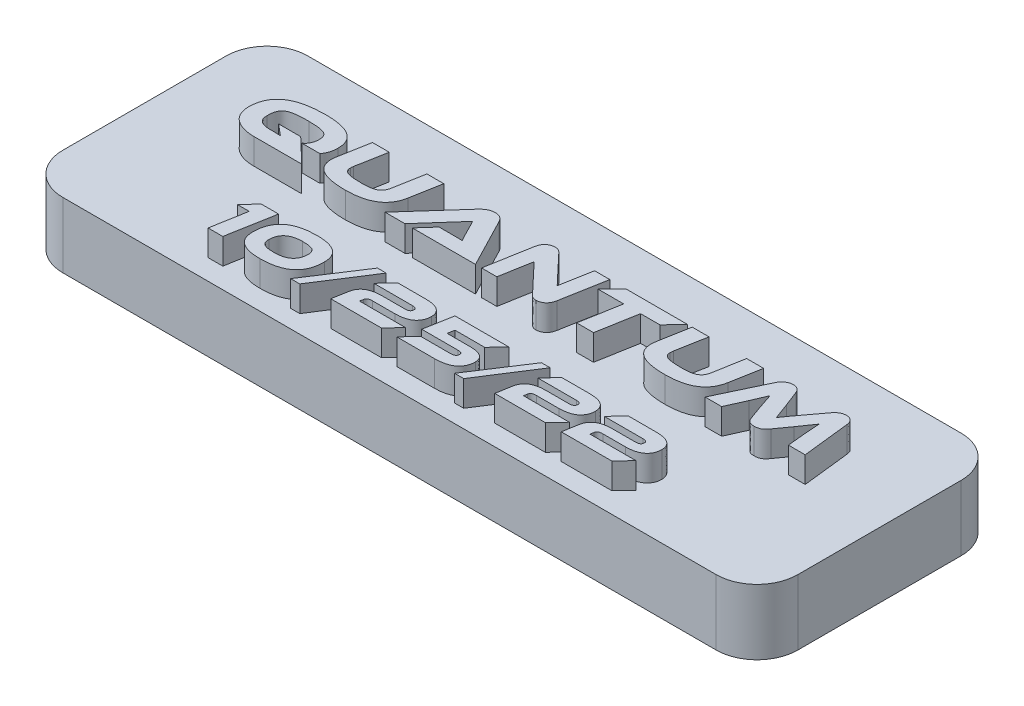
from build123d import *

# Parameters (mm, degrees)
SKETCH1_W           = 57.15
SKETCH1_H           = 19.05
BOSS_EXTRUDE1_DEPTH = 5.08
FILLET1_R           = 3.175
BOSS_EXTRUDE2_DEPTH = 2
SKETCH4_R           = 0.9
CUT_EXTRUDE1_DEPTH  = 4


with BuildPart() as part:
    # Sketch1 → Boss-Extrude1 (new body)
    with BuildSketch(Plane(origin=(0, 0, 0), x_dir=(1, 0, 0), z_dir=(0, 1, 0))):
        Rectangle(SKETCH1_W, SKETCH1_H)
    extrude(amount=BOSS_EXTRUDE1_DEPTH)

    # Fillet1
    fillet1_edges = [part.edges().sort_by_distance(p)[0] for p in [
        (-28.575, 2.54, -9.525),
        (-28.575, 2.54, 9.525),
        (28.575, 2.54, 9.525),
        (28.575, 2.54, -9.525),
    ]]
    fillet(fillet1_edges, radius=FILLET1_R)

    # Sketch3 → Boss-Extrude2 (add)
    with BuildSketch(Plane(origin=(0, 5.08, 0), x_dir=(1, 0, 0), z_dir=(0, 1, 0))):
        with BuildLine():
            add(Edge.make_bspline(
                [(18.242658301, 3.821864298), (18.228626929, 3.854947842), (18.20117453, 3.919675843), (18.146878265, 4.00785825), (18.083346334, 4.084680144), (18.01027638, 4.150072297), (17.925407832, 4.202261522), (17.828550464, 4.239681634), (17.719705347, 4.261491707), (17.643589857, 4.264690453), (17.603874928, 4.266359469)],
                knots=[0, 0, 0, 0, 0.000107692, 0.0002107, 0.00030937, 0.000405859, 0.000503537, 0.000606581, 0.000715765, 0.000834889, 0.000834889, 0.000834889, 0.000834889], degree=3))
            add(Edge.make_bspline(
                [(17.603874928, 4.266359469), (17.56259615, 4.264911976), (17.480084848, 4.262018611), (17.358319642, 4.234270285), (17.23991769, 4.188827027), (17.125926082, 4.125361681), (17.016789614, 4.045413244), (16.919972177, 3.943118147), (16.829908651, 3.825335584), (16.782034088, 3.735707046), (16.757367778, 3.689527923)],
                knots=[0, 0, 0, 0, 0.000123685, 0.000247231, 0.000372524, 0.000503046, 0.00063761, 0.000776601, 0.000924145, 0.00108096, 0.00108096, 0.00108096, 0.00108096], degree=3))
            Line((16.757367778, 3.689527923), (15.013783946, 0.003655726))
            Line((15.013783946, 0.003655726), (16.296487457, 0.003655726))
            Line((16.296487457, 0.003655726), (16.953636054, 1.464481009))
            add(Edge.make_bspline(
                [(16.953636054, 1.464481009), (16.977865812, 1.519909601), (17.025493838, 1.628864646), (17.094365231, 1.789446184), (17.161636319, 1.942964846), (17.224391525, 2.090413825), (17.284969187, 2.230959426), (17.341661284, 2.365338229), (17.394541541, 2.493505747), (17.428960337, 2.576699716), (17.445726184, 2.617224589)],
                knots=[0, 0, 0, 0, 0.000181479, 0.000356729, 0.00052418, 0.000684305, 0.000837469, 0.000983313, 0.001121843, 0.001253412, 0.001253412, 0.001253412, 0.001253412], degree=3))
            add(Edge.make_bspline(
                [(17.445726184, 2.617224589), (17.4559709, 2.582146896), (17.47721342, 2.509412955), (17.512585937, 2.396952832), (17.549310097, 2.276154433), (17.592645246, 2.146346616), (17.640529763, 2.002632754), (17.69660805, 1.841123618), (17.761748798, 1.659810645), (17.807449621, 1.531826555), (17.83149942, 1.464475652)],
                knots=[0, 0, 0, 0, 0.000109626, 0.000227311, 0.000353666, 0.000488379, 0.000637834, 0.000808115, 0.001001264, 0.001215812, 0.001215812, 0.001215812, 0.001215812], degree=3))
            Line((17.83149942, 1.464475652), (18.211064619, 0.404912456))
            add(Edge.make_bspline(
                [(18.211064619, 0.404912456), (18.229239325, 0.359535583), (18.263194741, 0.27475894), (18.32915974, 0.165066891), (18.400458371, 0.079389949), (18.481519793, 0.020148619), (18.570040737, -0.017188774), (18.6653744, -0.042938659), (18.769939175, -0.056575195), (18.842519564, -0.05604004), (18.880034734, -0.05576343)],
                knots=[0, 0, 0, 0, 0.000146435, 0.000273581, 0.000382454, 0.000478632, 0.000571543, 0.000669118, 0.00077423, 0.000886686, 0.000886686, 0.000886686, 0.000886686], degree=3))
            add(Edge.make_bspline(
                [(18.880034734, -0.05576343), (18.917850936, -0.055992745), (18.99224091, -0.056443841), (19.1016701, -0.042717291), (19.205783554, -0.015563104), (19.307848686, 0.022829401), (19.409032652, 0.083036928), (19.51025564, 0.169070984), (19.614708485, 0.280708265), (19.679879451, 0.367692811), (19.714657874, 0.414112029)],
                knots=[0, 0, 0, 0, 0.00011337, 0.000223015, 0.000329662, 0.000435594, 0.000549104, 0.000680897, 0.00083287, 0.001006773, 0.001006773, 0.001006773, 0.001006773], degree=3))
            Line((19.714657874, 0.414112029), (20.466853552, 1.465200548))
            add(Edge.make_bspline(
                [(20.466853552, 1.465200548), (20.513035851, 1.529169794), (20.601434083, 1.651614289), (20.726219205, 1.828381807), (20.839932507, 1.987679293), (20.94049218, 2.133154937), (21.032320436, 2.266547935), (21.11700732, 2.390994455), (21.195140755, 2.508743118), (21.244700795, 2.584889894), (21.268720676, 2.621795362)],
                knots=[0, 0, 0, 0, 0.000236691, 0.000453055, 0.000649121, 0.000823842, 0.000983589, 0.001134958, 0.00127542, 0.001407521, 0.001407521, 0.001407521, 0.001407521], degree=3))
            add(Edge.make_bspline(
                [(21.268720676, 2.621795362), (21.270954648, 2.536757041), (21.275545404, 2.362005428), (21.289585918, 2.139966033), (21.30225339, 1.952236415), (21.31583103, 1.800289613), (21.329013373, 1.638717755), (21.339306284, 1.52784762), (21.344595507, 1.470874734)],
                knots=[0, 0, 0, 0, 0.000255182, 0.000524392, 0.000667354, 0.000819643, 0.000982028, 0.00115368, 0.00115368, 0.00115368, 0.00115368], degree=3))
            Line((21.344595507, 1.470874734), (21.490488866, 0.003655726))
            Line((21.490488866, 0.003655726), (22.792148587, 0.003655726))
            Line((22.792148587, 0.003655726), (22.375111977, 3.690201933))
            add(Edge.make_bspline(
                [(22.375111977, 3.690201933), (22.367746579, 3.735767572), (22.353673096, 3.822832418), (22.308826278, 3.942054526), (22.249844088, 4.044898175), (22.170812965, 4.125995793), (22.080539998, 4.189905999), (21.978985664, 4.235155569), (21.867104165, 4.262540065), (21.789036598, 4.265057293), (21.748651836, 4.266359469)],
                knots=[0, 0, 0, 0, 0.000138154, 0.000263979, 0.000379994, 0.000491206, 0.000600771, 0.000710019, 0.000822876, 0.000943824, 0.000943824, 0.000943824, 0.000943824], degree=3))
            add(Edge.make_bspline(
                [(21.748651836, 4.266359469), (21.70680633, 4.264315029), (21.624932239, 4.26031492), (21.506004755, 4.237458819), (21.395100573, 4.198932407), (21.293079692, 4.144580626), (21.197494123, 4.0797862), (21.110011394, 4.002630646), (21.02630324, 3.917859546), (20.977930349, 3.853756483), (20.953337343, 3.821166184)],
                knots=[0, 0, 0, 0, 0.000125572, 0.000245692, 0.000361916, 0.000476404, 0.000591519, 0.00070753, 0.000825838, 0.000948192, 0.000948192, 0.000948192, 0.000948192], degree=3))
            Line((20.953337343, 3.821166184), (20.062454416, 2.63063338))
            add(Edge.make_bspline(
                [(20.062454416, 2.63063338), (20.033362193, 2.592038973), (19.97675682, 2.516944994), (19.894403746, 2.40752977), (19.817874467, 2.303579542), (19.744321831, 2.207146967), (19.676583973, 2.115786728), (19.614900781, 2.029366729), (19.55615978, 1.950451781), (19.486593746, 1.854220433), (19.406713414, 1.742020151), (19.318060484, 1.614517972), (19.238572969, 1.49522478), (19.188370896, 1.418793145), (19.164336812, 1.382201739)],
                knots=[0, 0, 0, 0, 0.000144993, 0.000282116, 0.00041083, 0.000532231, 0.000645954, 0.000752012, 0.000850745, 0.000941075, 0.001108235, 0.001263934, 0.001406932, 0.001538268, 0.001538268, 0.001538268, 0.001538268], degree=3))
            add(Edge.make_bspline(
                [(19.164336812, 1.382201739), (19.152259499, 1.418805813), (19.126533621, 1.496776135), (19.083301353, 1.619692211), (19.034973022, 1.756361741), (18.979747087, 1.906038253), (18.919718358, 2.069898911), (18.852797994, 2.24675863), (18.78067273, 2.43736016), (18.729898357, 2.568503977), (18.703602899, 2.636421836)],
                knots=[0, 0, 0, 0, 0.000115632, 0.000246309, 0.000390878, 0.000550518, 0.00072492, 0.000914406, 0.001117803, 0.001336294, 0.001336294, 0.001336294, 0.001336294], degree=3))
            Line((18.703602899, 2.636421836), (18.242658301, 3.821864298))
        make_face()
        with BuildLine():
            Line((15.352051497, 4.208766837), (14.037754303, 4.208766837))
            Line((14.037754303, 4.208766837), (13.614398957, 1.862388219))
            add(Edge.make_bspline(
                [(13.614398957, 1.862388219), (13.607674433, 1.827139312), (13.594641648, 1.758823487), (13.566320284, 1.660431879), (13.529014888, 1.570400798), (13.483686994, 1.487363307), (13.429764247, 1.412619114), (13.367876681, 1.344995689), (13.297783376, 1.285307175), (13.219178005, 1.232427909), (13.129361579, 1.187314428), (13.027858133, 1.147991514), (12.912747156, 1.116850242), (12.785140572, 1.090400749), (12.644449156, 1.069568326), (12.490654511, 1.055333672), (12.323812061, 1.047035371), (12.208239784, 1.046819269), (12.148200338, 1.046707005)],
                knots=[0, 0, 0, 0, 0.000107621, 0.000208581, 0.000306536, 0.000399412, 0.000491759, 0.000582339, 0.000673759, 0.000767316, 0.000865846, 0.000974664, 0.001093329, 0.001223132, 0.001365473, 0.001519746, 0.001686326, 0.001866423, 0.001866423, 0.001866423, 0.001866423], degree=3))
            add(Edge.make_bspline(
                [(12.148200338, 1.046707005), (12.07993764, 1.046621121), (11.948871643, 1.046456221), (11.760525892, 1.052429953), (11.588485331, 1.060533552), (11.433029085, 1.075472065), (11.294249971, 1.093422131), (11.171534782, 1.114517759), (11.065653937, 1.141999094), (10.974263588, 1.172526408), (10.897032789, 1.209629908), (10.830871348, 1.251845467), (10.775512293, 1.30043275), (10.730722534, 1.354972316), (10.697242199, 1.415773277), (10.674111142, 1.4824615), (10.662333326, 1.555465653), (10.662574777, 1.605828027), (10.66269913, 1.631765942)],
                knots=[0, 0, 0, 0, 0.000204773, 0.000393168, 0.000565272, 0.000721365, 0.000861515, 0.000985061, 0.001094592, 0.001189417, 0.001273644, 0.00135098, 0.001424164, 0.001493694, 0.001561619, 0.001631293, 0.001704482, 0.001782207, 0.001782207, 0.001782207, 0.001782207], degree=3))
            add(Edge.make_bspline(
                [(10.66269913, 1.631765942), (10.663561153, 1.668081018), (10.665392705, 1.745240135), (10.676184016, 1.821673195), (10.681896377, 1.862132899)],
                knots=[0, 0, 0, 0, 0.00010888, 0.00023134, 0.00023134, 0.00023134, 0.00023134], degree=3))
            Line((10.681896377, 1.862132899), (11.112179301, 4.208766837))
            Line((11.112179301, 4.208766837), (9.804200844, 4.208766837))
            Line((9.804200844, 4.208766837), (9.380845498, 1.862388219))
            add(Edge.make_bspline(
                [(9.380845498, 1.862388219), (9.369504435, 1.795424142), (9.347501048, 1.665503639), (9.344240088, 1.533787249), (9.342659903, 1.46996058)],
                knots=[0, 0, 0, 0, 0.000203453, 0.00039473, 0.00039473, 0.00039473, 0.00039473], degree=3))
            add(Edge.make_bspline(
                [(9.342659903, 1.46996058), (9.343858856, 1.40859245), (9.346193223, 1.289108399), (9.375412688, 1.115562884), (9.42327125, 0.953539335), (9.492998987, 0.803554728), (9.581937977, 0.665184035), (9.692692082, 0.540177804), (9.82172526, 0.425561456), (9.97238054, 0.324145254), (10.143623569, 0.234151547), (10.337431705, 0.15809302), (10.552892881, 0.09238014), (10.791044837, 0.039293588), (11.051099084, -0.002721651), (11.333504841, -0.030740825), (11.638152289, -0.049583047), (11.848936, -0.051848282), (11.958056184, -0.053020966)],
                knots=[0, 0, 0, 0, 0.000183929, 0.000358111, 0.000526139, 0.000689333, 0.000852629, 0.001017828, 0.001188792, 0.001369069, 0.001561259, 0.001768019, 0.001992702, 0.002236425, 0.002499429, 0.002782504, 0.003087466, 0.003414796, 0.003414796, 0.003414796, 0.003414796], degree=3))
            add(Edge.make_bspline(
                [(11.958056184, -0.053020966), (12.065056301, -0.051404013), (12.273213812, -0.0482584), (12.576237093, -0.025020937), (12.861495902, 0.011650769), (13.128740953, 0.064516757), (13.378157942, 0.131877218), (13.609733174, 0.213665603), (13.822809311, 0.311958663), (14.018545755, 0.424179889), (14.196098268, 0.552059501), (14.356481142, 0.694108361), (14.497944512, 0.852282745), (14.620897907, 1.025501425), (14.727014829, 1.21259616), (14.812196251, 1.415894135), (14.883293531, 1.632639003), (14.912998722, 1.784635018), (14.928144444, 1.862132899)],
                knots=[0, 0, 0, 0, 0.000320974, 0.000624421, 0.000911183, 0.001183331, 0.001441019, 0.001685636, 0.00191919, 0.002144039, 0.002361465, 0.002574487, 0.002785536, 0.002996585, 0.003210663, 0.003429366, 0.003656887, 0.00389357, 0.00389357, 0.00389357, 0.00389357], degree=3))
            Line((14.928144444, 1.862132899), (15.352051497, 4.208766837))
        make_face()
        Polygon((4.64094681, 4.206347541), (3.59203655, 3.106887389), (5.576119813, 3.106887389), (5.026389737, 0.003655726), (6.334368194, 0.003655726), (6.890417006, 3.106887389), (8.394276295, 3.106887389), (9.443186555, 4.206347541), align=None)
        with BuildLine():
            add(Edge.make_bspline(
                [(1.919769274, -0.054850168), (1.967512671, -0.053307756), (2.062214813, -0.05024828), (2.200271195, -0.013632566), (2.331185906, 0.045846546), (2.43245144, 0.114571327), (2.509316104, 0.180074196), (2.560968385, 0.239380304), (2.608644372, 0.304525883), (2.652323119, 0.37632488), (2.689052754, 0.456142621), (2.722169375, 0.542520209), (2.750599028, 0.636006561), (2.765145102, 0.701351948), (2.77263087, 0.73498029)],
                knots=[0, 0, 0, 0, 0.000142918, 0.000283487, 0.000425039, 0.000572601, 0.000649052, 0.000727397, 0.000807848, 0.000891096, 0.000979017, 0.001071034, 0.001168489, 0.001271817, 0.001271817, 0.001271817, 0.001271817], degree=3))
            Line((2.77263087, 0.73498029), (3.398353617, 4.208766837))
            Line((3.398353617, 4.208766837), (2.210431153, 4.208766837))
            Line((2.210431153, 4.208766837), (1.768119598, 1.744535481))
            Line((1.768119598, 1.744535481), (-0.411844497, 4.051761679))
            add(Edge.make_bspline(
                [(-0.411844497, 4.051761679), (-0.432683624, 4.071861366), (-0.472747897, 4.110504029), (-0.535325761, 4.159915527), (-0.597363507, 4.198286334), (-0.677200889, 4.234148727), (-0.777477457, 4.262967857), (-0.858799888, 4.265244744), (-0.898613961, 4.266359469)],
                knots=[0, 0, 0, 0, 8.6821e-05, 0.000166918, 0.000238724, 0.000304999, 0.000429193, 0.000548317, 0.000548317, 0.000548317, 0.000548317], degree=3))
            add(Edge.make_bspline(
                [(-0.898613961, 4.266359469), (-0.947891006, 4.264808905), (-1.044937594, 4.261755212), (-1.186080306, 4.225895662), (-1.319816011, 4.169094021), (-1.422375014, 4.10078741), (-1.498890246, 4.035125752), (-1.550765611, 3.976716804), (-1.598914, 3.912614286), (-1.640976697, 3.840326612), (-1.678292296, 3.76109782), (-1.709863622, 3.674633708), (-1.738078407, 3.581734028), (-1.75116106, 3.516584051), (-1.757919275, 3.482928986)],
                knots=[0, 0, 0, 0, 0.000147522, 0.000290531, 0.000433852, 0.000581668, 0.000658119, 0.000735785, 0.0008155, 0.00089828, 0.000986201, 0.001077895, 0.001174211, 0.001277134, 0.001277134, 0.001277134, 0.001277134], degree=3))
            Line((-1.757919275, 3.482928986), (-2.370652814, 0.003655726))
            Line((-2.370652814, 0.003655726), (-1.182730351, 0.003655726))
            Line((-1.182730351, 0.003655726), (-0.746737532, 2.467622834))
            Line((-0.746737532, 2.467622834), (1.433226563, 0.160396636))
            add(Edge.make_bspline(
                [(1.433226563, 0.160396636), (1.453943669, 0.140042889), (1.493548567, 0.101132624), (1.555680119, 0.052046216), (1.615239946, 0.012533377), (1.692768817, -0.024191848), (1.794462998, -0.051598076), (1.877492762, -0.054359084), (1.919769274, -0.054850168)],
                knots=[0, 0, 0, 0, 8.7067e-05, 0.000166446, 0.000237191, 0.000300979, 0.000423168, 0.000549653, 0.000549653, 0.000549653, 0.000549653], degree=3))
        make_face()
        with BuildLine():
            Line((-2.843742098, 0.006075914), (-4.808869152, 3.800574494))
            add(Edge.make_bspline(
                [(-4.808869152, 3.800574494), (-4.826990096, 3.832806008), (-4.862948759, 3.896765269), (-4.927822449, 3.985575321), (-5.005081936, 4.0630874), (-5.089984848, 4.133983071), (-5.187790741, 4.192399523), (-5.299901891, 4.23493807), (-5.425943718, 4.260058315), (-5.514674651, 4.264204191), (-5.560802367, 4.266359469)],
                knots=[0, 0, 0, 0, 0.000110886, 0.000220038, 0.000328642, 0.000438436, 0.000551159, 0.000668641, 0.000796469, 0.000934872, 0.000934872, 0.000934872, 0.000934872], degree=3))
            add(Edge.make_bspline(
                [(-5.560802367, 4.266359469), (-5.610614027, 4.264009128), (-5.707345148, 4.259444915), (-5.847383903, 4.230967468), (-5.977662466, 4.187726952), (-6.097397341, 4.126959855), (-6.207078996, 4.055096369), (-6.31028035, 3.977511138), (-6.404586563, 3.892229282), (-6.461969066, 3.830720556), (-6.490497585, 3.800140628)],
                knots=[0, 0, 0, 0, 0.00014941, 0.000290146, 0.000427171, 0.000560039, 0.000691642, 0.000820174, 0.000947034, 0.001072464, 0.001072464, 0.001072464, 0.001072464], degree=3))
            Line((-6.490497585, 3.800140628), (-9.876495831, 0.006075914))
            Line((-9.876495831, 0.006075914), (-8.328405386, 0.006075914))
            Line((-8.328405386, 0.006075914), (-5.851460676, 2.798493231))
            Line((-5.851460676, 2.798493231), (-5.289093126, 1.696826253))
            add(Edge.make_bspline(
                [(-5.289093126, 1.696826253), (-5.262419122, 1.644325557), (-5.207902875, 1.5370248), (-5.138474534, 1.403208105), (-5.082391439, 1.297464771), (-5.041250325, 1.223921613), (-5.004846483, 1.155498073), (-4.979548178, 1.112747401), (-4.967516039, 1.092414734)],
                knots=[0, 0, 0, 0, 0.000176664, 0.000361065, 0.000452265, 0.000535729, 0.000613867, 0.000684736, 0.000684736, 0.000684736, 0.000684736], degree=3))
            add(Edge.make_bspline(
                [(-4.967516039, 1.092414734), (-5.022964383, 1.095166522), (-5.141124218, 1.101030553), (-5.325554754, 1.103502684), (-5.52057362, 1.10564963), (-5.652826217, 1.105358474), (-5.718951111, 1.105212899)],
                knots=[0, 0, 0, 0, 0.000166537, 0.000354888, 0.000553268, 0.00075164, 0.00075164, 0.00075164, 0.00075164], degree=3))
            Line((-5.718951111, 1.105212899), (-6.773996206, 1.105536066))
            Line((-6.773996206, 1.105536066), (-7.759719101, 0.006075914))
            Line((-7.759719101, 0.006075914), (-2.843742098, 0.006075914))
        make_face()
        with BuildLine():
            Line((-9.512953334, 4.208766837), (-10.827250527, 4.208766837))
            Line((-10.827250527, 4.208766837), (-11.250605873, 1.862388219))
            add(Edge.make_bspline(
                [(-11.250605873, 1.862388219), (-11.257330398, 1.827139312), (-11.270363182, 1.758823487), (-11.298684547, 1.660431879), (-11.335989943, 1.570400798), (-11.381317837, 1.487363307), (-11.435240584, 1.412619114), (-11.49712815, 1.344995689), (-11.567221455, 1.285307175), (-11.645826826, 1.232427909), (-11.735643252, 1.187314428), (-11.837146698, 1.147991514), (-11.952257675, 1.116850242), (-12.079864259, 1.090400749), (-12.220555675, 1.069568326), (-12.37435032, 1.055333672), (-12.54119277, 1.047035371), (-12.656765047, 1.046819269), (-12.716804493, 1.046707005)],
                knots=[0, 0, 0, 0, 0.000107621, 0.000208581, 0.000306536, 0.000399412, 0.000491759, 0.000582339, 0.000673759, 0.000767316, 0.000865846, 0.000974664, 0.001093329, 0.001223132, 0.001365473, 0.001519746, 0.001686326, 0.001866423, 0.001866423, 0.001866423, 0.001866423], degree=3))
            add(Edge.make_bspline(
                [(-12.716804493, 1.046707005), (-12.785067191, 1.046621121), (-12.916133188, 1.046456221), (-13.104478939, 1.052429953), (-13.2765195, 1.060533552), (-13.431975746, 1.075472065), (-13.57075486, 1.093422131), (-13.693470049, 1.114517759), (-13.799350894, 1.141999094), (-13.890741243, 1.172526408), (-13.967972042, 1.209629908), (-14.034133483, 1.251845467), (-14.089492538, 1.30043275), (-14.134282297, 1.354972316), (-14.167762631, 1.415773277), (-14.190893689, 1.4824615), (-14.202671505, 1.555465653), (-14.202430054, 1.605828027), (-14.2023057, 1.631765942)],
                knots=[0, 0, 0, 0, 0.000204773, 0.000393168, 0.000565272, 0.000721365, 0.000861515, 0.000985061, 0.001094592, 0.001189417, 0.001273644, 0.00135098, 0.001424164, 0.001493694, 0.001561619, 0.001631293, 0.001704482, 0.001782207, 0.001782207, 0.001782207, 0.001782207], degree=3))
            add(Edge.make_bspline(
                [(-14.2023057, 1.631765942), (-14.201443678, 1.668081018), (-14.199612126, 1.745240135), (-14.188820815, 1.821673195), (-14.183108454, 1.862132899)],
                knots=[0, 0, 0, 0, 0.00010888, 0.00023134, 0.00023134, 0.00023134, 0.00023134], degree=3))
            Line((-14.183108454, 1.862132899), (-13.75282553, 4.208766837))
            Line((-13.75282553, 4.208766837), (-15.060803987, 4.208766837))
            Line((-15.060803987, 4.208766837), (-15.484159333, 1.862388219))
            add(Edge.make_bspline(
                [(-15.484159333, 1.862388219), (-15.495500396, 1.795424142), (-15.517503783, 1.665503639), (-15.520764743, 1.533787249), (-15.522344928, 1.46996058)],
                knots=[0, 0, 0, 0, 0.000203453, 0.00039473, 0.00039473, 0.00039473, 0.00039473], degree=3))
            add(Edge.make_bspline(
                [(-15.522344928, 1.46996058), (-15.521145975, 1.40859245), (-15.518811608, 1.289108399), (-15.489592143, 1.115562884), (-15.441733581, 0.953539335), (-15.372005844, 0.803554728), (-15.283066854, 0.665184035), (-15.172312749, 0.540177804), (-15.04327957, 0.425561456), (-14.892624291, 0.324145254), (-14.721381261, 0.234151547), (-14.527573126, 0.15809302), (-14.31211195, 0.09238014), (-14.073959994, 0.039293588), (-13.813905747, -0.002721651), (-13.53149999, -0.030740825), (-13.226852541, -0.049583047), (-13.016068831, -0.051848282), (-12.906948647, -0.053020966)],
                knots=[0, 0, 0, 0, 0.000183929, 0.000358111, 0.000526139, 0.000689333, 0.000852629, 0.001017828, 0.001188792, 0.001369069, 0.001561259, 0.001768019, 0.001992702, 0.002236425, 0.002499429, 0.002782504, 0.003087466, 0.003414796, 0.003414796, 0.003414796, 0.003414796], degree=3))
            add(Edge.make_bspline(
                [(-12.906948647, -0.053020966), (-12.799948529, -0.051404013), (-12.591791018, -0.0482584), (-12.288767737, -0.025020937), (-12.003508928, 0.011650769), (-11.736263878, 0.064516757), (-11.486846889, 0.131877218), (-11.255271657, 0.213665603), (-11.04219552, 0.311958663), (-10.846459076, 0.424179889), (-10.668906562, 0.552059501), (-10.508523689, 0.694108361), (-10.367060319, 0.852282745), (-10.244106923, 1.025501425), (-10.137990002, 1.21259616), (-10.05280858, 1.415894135), (-9.9817113, 1.632639003), (-9.952006109, 1.784635018), (-9.936860386, 1.862132899)],
                knots=[0, 0, 0, 0, 0.000320974, 0.000624421, 0.000911183, 0.001183331, 0.001441019, 0.001685636, 0.00191919, 0.002144039, 0.002361465, 0.002574487, 0.002785536, 0.002996585, 0.003210663, 0.003429366, 0.003656887, 0.00389357, 0.00389357, 0.00389357, 0.00389357], degree=3))
            Line((-9.936860386, 1.862132899), (-9.512953334, 4.208766837))
        make_face()
        with BuildLine():
            Line((-18.244170585, 1.814737911), (-19.950229442, 1.814737911))
            Line((-19.950229442, 1.814737911), (-19.48264294, 1.407717722))
            add(Edge.make_bspline(
                [(-19.48264294, 1.407717722), (-19.450826218, 1.378825364), (-19.385354675, 1.319371495), (-19.283037904, 1.235802838), (-19.182544102, 1.157025486), (-19.116019259, 1.108693391), (-19.084805362, 1.086015652)],
                knots=[0, 0, 0, 0, 0.000128912, 0.000265271, 0.0003962, 0.000511937, 0.000511937, 0.000511937, 0.000511937], degree=3))
            add(Edge.make_bspline(
                [(-19.084805362, 1.086015652), (-19.124713871, 1.088909965), (-19.2075291, 1.094916032), (-19.33370751, 1.101068962), (-19.462327522, 1.104853502), (-19.547974492, 1.10509397), (-19.59033285, 1.105212899)],
                knots=[0, 0, 0, 0, 0.000120037, 0.000249091, 0.000378953, 0.000506023, 0.000506023, 0.000506023, 0.000506023], degree=3))
            Line((-19.59033285, 1.105212899), (-19.868085867, 1.105536066))
            add(Edge.make_bspline(
                [(-19.868085867, 1.105536066), (-19.909894984, 1.105205693), (-19.991404052, 1.104561612), (-20.109829598, 1.112376395), (-20.22134154, 1.124654912), (-20.325428197, 1.143951385), (-20.422641903, 1.168404051), (-20.512547899, 1.198547113), (-20.595463011, 1.234005309), (-20.670725121, 1.276019688), (-20.738595414, 1.324680674), (-20.797738726, 1.381720087), (-20.84743365, 1.447683668), (-20.888949456, 1.52133674), (-20.920799709, 1.603289095), (-20.943415716, 1.693275036), (-20.958309127, 1.790953629), (-20.960457197, 1.859028932), (-20.961564734, 1.894128309)],
                knots=[0, 0, 0, 0, 0.000125391, 0.000244455, 0.000355806, 0.000461773, 0.000561768, 0.000656298, 0.000745964, 0.000831914, 0.000914381, 0.000995838, 0.001077382, 0.001161291, 0.001248715, 0.001340286, 0.001439188, 0.001544459, 0.001544459, 0.001544459, 0.001544459], degree=3))
            add(Edge.make_bspline(
                [(-20.961564734, 1.894128309), (-20.963200651, 1.953861498), (-20.966342774, 2.068591717), (-20.954492598, 2.233888938), (-20.929343515, 2.384294274), (-20.891419505, 2.520274492), (-20.839205658, 2.641381833), (-20.773285324, 2.748021206), (-20.692474617, 2.838726959), (-20.614270486, 2.902389891), (-20.543958867, 2.946048181), (-20.483809271, 2.976119005), (-20.417337183, 3.004466466), (-20.344066093, 3.02943159), (-20.26475266, 3.053976034), (-20.178417167, 3.074085034), (-20.085788554, 3.093456663), (-19.98676833, 3.110958744), (-19.880946759, 3.125517572), (-19.768336988, 3.136617694), (-19.649632059, 3.148657949), (-19.523915484, 3.154752611), (-19.39202771, 3.161877757), (-19.253333938, 3.165300971), (-19.108267683, 3.166047406), (-19.009234891, 3.16522384), (-18.958652029, 3.164803188)],
                knots=[0, 0, 0, 0, 0.000179184, 0.00034416, 0.000496251, 0.000636009, 0.000766608, 0.00089064, 0.001010437, 0.001129365, 0.001191769, 0.001258408, 0.001330909, 0.001408391, 0.001490523, 0.001579877, 0.001674181, 0.001774426, 0.001881472, 0.001994539, 0.002113884, 0.002239337, 0.002372044, 0.002510129, 0.002655483, 0.002807235, 0.002807235, 0.002807235, 0.002807235], degree=3))
            add(Edge.make_bspline(
                [(-18.958652029, 3.164803188), (-18.889786779, 3.165086646), (-18.756608933, 3.165634822), (-18.564186461, 3.161832077), (-18.386493886, 3.150341934), (-18.223198873, 3.135653164), (-18.07454971, 3.114010201), (-17.940414843, 3.086276067), (-17.820382555, 3.055549905), (-17.714756921, 3.016703073), (-17.621226609, 2.971771779), (-17.541919387, 2.914022318), (-17.473995733, 2.847512799), (-17.417893393, 2.770771553), (-17.377068596, 2.682228656), (-17.348104754, 2.584627778), (-17.33012835, 2.477106469), (-17.329199021, 2.40216825), (-17.328714396, 2.363089614)],
                knots=[0, 0, 0, 0, 0.000206599, 0.00039954, 0.000577225, 0.000740685, 0.000891298, 0.001027553, 0.001151508, 0.001262569, 0.001364775, 0.001461693, 0.001555424, 0.001649048, 0.001745143, 0.001846362, 0.001953817, 0.002070918, 0.002070918, 0.002070918, 0.002070918], degree=3))
            add(Edge.make_bspline(
                [(-17.328714396, 2.363089614), (-17.329594148, 2.314580404), (-17.331321568, 2.219331165), (-17.350034271, 2.079979057), (-17.380967703, 1.947199102), (-17.425344912, 1.821565643), (-17.485074938, 1.704426881), (-17.560587836, 1.596585207), (-17.654986015, 1.500909288), (-17.727734772, 1.447081887), (-17.764766135, 1.419682077)],
                knots=[0, 0, 0, 0, 0.000145454, 0.000285603, 0.000420861, 0.00055387, 0.00068429, 0.000814151, 0.000947317, 0.001085382, 0.001085382, 0.001085382, 0.001085382], degree=3))
            Line((-17.764766135, 1.419682077), (-16.361187105, 1.420051667))
            add(Edge.make_bspline(
                [(-16.361187105, 1.420051667), (-16.336375039, 1.451828572), (-16.285848029, 1.516538699), (-16.219274268, 1.622794771), (-16.161188821, 1.738519442), (-16.109040942, 1.862986831), (-16.066244323, 1.999771018), (-16.036955418, 2.15120247), (-16.018767494, 2.31725184), (-16.015736023, 2.432820561), (-16.014160097, 2.492899565)],
                knots=[0, 0, 0, 0, 0.000120893, 0.000246186, 0.000375376, 0.000508984, 0.000650663, 0.000804486, 0.000970955, 0.001151192, 0.001151192, 0.001151192, 0.001151192], degree=3))
            add(Edge.make_bspline(
                [(-16.014160097, 2.492899565), (-16.016206638, 2.565851518), (-16.020183659, 2.707618203), (-16.052731072, 2.913233204), (-16.106009679, 3.104578143), (-16.182685692, 3.280936661), (-16.28033022, 3.442473517), (-16.399513022, 3.589365497), (-16.540910161, 3.721035504), (-16.704425521, 3.837071214), (-16.888457312, 3.940135758), (-17.094500179, 4.026622074), (-17.320366899, 4.102333882), (-17.56838491, 4.161421516), (-17.837003411, 4.208718586), (-18.126959771, 4.242297194), (-18.437940372, 4.261022072), (-18.65238477, 4.263336881), (-18.763022947, 4.264531159)],
                knots=[0, 0, 0, 0, 0.000218758, 0.00042511, 0.000622756, 0.000813133, 0.001000168, 0.00118734, 0.001378785, 0.001577933, 0.00178748, 0.002010263, 0.00224731, 0.002501399, 0.002774332, 0.003065178, 0.003376583, 0.003708483, 0.003708483, 0.003708483, 0.003708483], degree=3))
            add(Edge.make_bspline(
                [(-18.763022947, 4.264531159), (-18.835857336, 4.26396195), (-18.979124797, 4.262842297), (-19.190345316, 4.255284336), (-19.394620664, 4.243831181), (-19.591817368, 4.226284328), (-19.782035323, 4.204411552), (-19.965076295, 4.178311021), (-20.140898458, 4.145997495), (-20.30984759, 4.109627023), (-20.47195597, 4.068814492), (-20.626485655, 4.022064859), (-20.774018162, 3.970664471), (-20.915092749, 3.915559782), (-21.048319531, 3.853393341), (-21.176207693, 3.789824284), (-21.294616329, 3.71721344), (-21.407969587, 3.643084217), (-21.512624279, 3.561837109), (-21.612630326, 3.47794445), (-21.704064979, 3.387348497), (-21.790125877, 3.293139714), (-21.867210044, 3.193032916), (-21.939610609, 3.089277048), (-22.003872327, 2.97993464), (-22.061936486, 2.865780458), (-22.112931327, 2.747308492), (-22.15714091, 2.623644078), (-22.194409239, 2.495430879), (-22.224488543, 2.361965621), (-22.248382135, 2.224397103), (-22.264483588, 2.081532075), (-22.27502559, 1.934207805), (-22.275751859, 1.834117569), (-22.276119034, 1.783515604)],
                knots=[0, 0, 0, 0, 0.0002185, 0.000429796, 0.000633999, 0.000832219, 0.001023625, 0.001208368, 0.001386778, 0.001559804, 0.001726757, 0.00188813, 0.002043958, 0.00219538, 0.002342229, 0.002484913, 0.002623504, 0.002758641, 0.002891017, 0.003020711, 0.003149998, 0.003276858, 0.003403217, 0.003528736, 0.003656197, 0.003783344, 0.003912741, 0.00404286, 0.004177094, 0.004313036, 0.004453105, 0.004595751, 0.004744185, 0.004895959, 0.004895959, 0.004895959, 0.004895959], degree=3))
            add(Edge.make_bspline(
                [(-22.276119034, 1.783515604), (-22.272930233, 1.713310852), (-22.266714105, 1.576456331), (-22.234493254, 1.377752837), (-22.183218537, 1.192440072), (-22.114538053, 1.019301325), (-22.026368393, 0.859824815), (-21.920049604, 0.712619731), (-21.795161086, 0.578636305), (-21.651740999, 0.458966909), (-21.493450629, 0.35378252), (-21.323277333, 0.260627121), (-21.141117363, 0.182196288), (-20.947055513, 0.118329561), (-20.741722344, 0.067842124), (-20.524326798, 0.032937665), (-20.295306087, 0.010498745), (-20.138574808, 0.007182006), (-20.05838, 0.005484928)],
                knots=[0, 0, 0, 0, 0.000210702, 0.000410735, 0.000602359, 0.000786542, 0.000968209, 0.001147593, 0.001329993, 0.001516214, 0.001706624, 0.001899305, 0.002097482, 0.002300707, 0.002511559, 0.002731128, 0.002960717, 0.003201281, 0.003201281, 0.003201281, 0.003201281], degree=3))
            Line((-20.05838, 0.005484928), (-16.354868369, 0.006075914))
            Line((-16.354868369, 0.006075914), (-18.244170585, 1.814737911))
        make_face()
        with BuildLine():
            Line((12.393961292, -5.218973535), (15.385093186, -5.218973535))
            add(Edge.make_bspline(
                [(15.385093186, -5.218973535), (15.4127941, -5.218922741), (15.464640475, -5.218827674), (15.537369478, -5.225918073), (15.598893519, -5.242216387), (15.650724056, -5.26353583), (15.690817446, -5.294908436), (15.719131445, -5.334273792), (15.736683422, -5.381008794), (15.737908122, -5.4147712), (15.738542488, -5.432259348)],
                knots=[0, 0, 0, 0, 8.3099e-05, 0.000155531, 0.000218392, 0.000273538, 0.000322508, 0.000368908, 0.000417497, 0.000469711, 0.000469711, 0.000469711, 0.000469711], degree=3))
            add(Edge.make_bspline(
                [(15.738542488, -5.432259348), (15.737902695, -5.458018948), (15.73669309, -5.506720508), (15.716130704, -5.573936821), (15.682844328, -5.630194031), (15.633630705, -5.673414306), (15.570099606, -5.704561408), (15.492365439, -5.726311626), (15.39924028, -5.738498194), (15.332238635, -5.73961472), (15.296205936, -5.740215175)],
                knots=[0, 0, 0, 0, 7.6993e-05, 0.000145564, 0.000208395, 0.000270703, 0.000339032, 0.00041902, 0.000511893, 0.000619952, 0.000619952, 0.000619952, 0.000619952], degree=3))
            Line((15.296205936, -5.740215175), (13.538442442, -5.739416071))
            add(Edge.make_bspline(
                [(13.538442442, -5.739416071), (13.482840286, -5.740560639), (13.374587124, -5.742789025), (13.216591798, -5.753609346), (13.067872438, -5.772857955), (12.92824957, -5.798779792), (12.797986372, -5.833149331), (12.67690752, -5.875619954), (12.56464014, -5.92500466), (12.461438272, -5.98174212), (12.367969075, -6.047028209), (12.283443582, -6.120143527), (12.208042973, -6.201107035), (12.142041951, -6.289606037), (12.085660378, -6.385733808), (12.038564623, -6.489539314), (11.99961726, -6.600822081), (11.982295584, -6.678800473), (11.973482542, -6.718474855)],
                knots=[0, 0, 0, 0, 0.000166829, 0.000324804, 0.000474816, 0.000616477, 0.000750546, 0.000878553, 0.001001026, 0.001118108, 0.001231277, 0.001342418, 0.001452782, 0.001562526, 0.00167296, 0.001786425, 0.001904052, 0.002025887, 0.002025887, 0.002025887, 0.002025887], degree=3))
            Line((11.973482542, -6.718474855), (11.758138431, -7.932183575))
            Line((11.758138431, -7.932183575), (15.694711275, -7.932183575))
            Line((15.694711275, -7.932183575), (16.601449964, -6.970155942))
            Line((16.601449964, -6.970155942), (13.029784153, -6.970155942))
            Line((13.029784153, -6.970155942), (13.079544203, -6.707239748))
            add(Edge.make_bspline(
                [(13.079544203, -6.707239748), (13.083321727, -6.686112106), (13.090644484, -6.645156023), (13.119355837, -6.590591717), (13.15771653, -6.543848716), (13.209055861, -6.508043577), (13.270131328, -6.47963759), (13.342448948, -6.461031101), (13.425512369, -6.450993538), (13.48443588, -6.450679637), (13.515661335, -6.450513291)],
                knots=[0, 0, 0, 0, 6.4036e-05, 0.000124134, 0.000182613, 0.000243892, 0.000310094, 0.000383827, 0.000466868, 0.000560486, 0.000560486, 0.000560486, 0.000560486], degree=3))
            Line((13.515661335, -6.450513291), (15.274515297, -6.449714187))
            add(Edge.make_bspline(
                [(15.274515297, -6.449714187), (15.340196322, -6.448593152), (15.467530763, -6.446419826), (15.651428612, -6.426694059), (15.822845222, -6.400940141), (15.980692108, -6.361961645), (16.126446102, -6.315052912), (16.257787357, -6.255202462), (16.377260472, -6.187512089), (16.481972912, -6.107690588), (16.574556104, -6.020066732), (16.655012466, -5.925525662), (16.72279135, -5.823724541), (16.778544152, -5.715194429), (16.820680121, -5.599220599), (16.851375557, -5.476792913), (16.869030903, -5.347458364), (16.870983856, -5.259004345), (16.871979909, -5.21389067)],
                knots=[0, 0, 0, 0, 0.00019697, 0.000381861, 0.000554393, 0.000716581, 0.000869107, 0.001013024, 0.00114885, 0.001280192, 0.001406932, 0.001530654, 0.001651783, 0.001773055, 0.001895792, 0.002021116, 0.002151095, 0.002286391, 0.002286391, 0.002286391, 0.002286391], degree=3))
            add(Edge.make_bspline(
                [(16.871979909, -5.21389067), (16.871527455, -5.1780961), (16.87064171, -5.108023129), (16.854431863, -5.005989197), (16.83043979, -4.909275966), (16.793905087, -4.818686266), (16.746270734, -4.734234215), (16.688191692, -4.655338408), (16.619824066, -4.582231577), (16.540529625, -4.515185386), (16.449706709, -4.455053695), (16.346128088, -4.402688892), (16.229894968, -4.359688685), (16.101707488, -4.322394884), (15.960904479, -4.294289614), (15.807557434, -4.27367202), (15.641690903, -4.26108405), (15.526861287, -4.258543735), (15.467381383, -4.257227893)],
                knots=[0, 0, 0, 0, 0.000107259, 0.000209975, 0.000309113, 0.00040566, 0.000501999, 0.00059927, 0.000698874, 0.0008016, 0.000910084, 0.001024914, 0.001148961, 0.001281358, 0.001425053, 0.00157924, 0.00174531, 0.001923772, 0.001923772, 0.001923772, 0.001923772], degree=3))
            Line((15.467381383, -4.257227893), (13.300699981, -4.256945902))
            Line((13.300699981, -4.256945902), (12.393961292, -5.218973535))
        make_face()
        with BuildLine():
            Line((7.223502934, -5.218973535), (10.214634829, -5.218973535))
            add(Edge.make_bspline(
                [(10.214634829, -5.218973535), (10.242335743, -5.218922741), (10.294182117, -5.218827674), (10.36691112, -5.225918073), (10.428435162, -5.242216387), (10.480265699, -5.26353583), (10.520359088, -5.294908436), (10.548673087, -5.334273792), (10.566225065, -5.381008794), (10.567449764, -5.4147712), (10.56808413, -5.432259348)],
                knots=[0, 0, 0, 0, 8.3099e-05, 0.000155531, 0.000218392, 0.000273538, 0.000322508, 0.000368908, 0.000417497, 0.000469711, 0.000469711, 0.000469711, 0.000469711], degree=3))
            add(Edge.make_bspline(
                [(10.56808413, -5.432259348), (10.567444337, -5.458018948), (10.566234732, -5.506720508), (10.545672347, -5.573936821), (10.51238597, -5.630194031), (10.463172347, -5.673414306), (10.399641249, -5.704561408), (10.321907082, -5.726311626), (10.228781922, -5.738498194), (10.161780278, -5.73961472), (10.125747579, -5.740215175)],
                knots=[0, 0, 0, 0, 7.6993e-05, 0.000145564, 0.000208395, 0.000270703, 0.000339032, 0.00041902, 0.000511893, 0.000619952, 0.000619952, 0.000619952, 0.000619952], degree=3))
            Line((10.125747579, -5.740215175), (8.367984084, -5.739416071))
            add(Edge.make_bspline(
                [(8.367984084, -5.739416071), (8.312381928, -5.740560639), (8.204128766, -5.742789025), (8.04613344, -5.753609346), (7.89741408, -5.772857955), (7.757791212, -5.798779792), (7.627528014, -5.833149331), (7.506449162, -5.875619954), (7.394181782, -5.92500466), (7.290979914, -5.98174212), (7.197510718, -6.047028209), (7.112985225, -6.120143527), (7.037584616, -6.201107035), (6.971583593, -6.289606037), (6.91520202, -6.385733808), (6.868106265, -6.489539314), (6.829158902, -6.600822081), (6.811837226, -6.678800473), (6.803024185, -6.718474855)],
                knots=[0, 0, 0, 0, 0.000166829, 0.000324804, 0.000474816, 0.000616477, 0.000750546, 0.000878553, 0.001001026, 0.001118108, 0.001231277, 0.001342418, 0.001452782, 0.001562526, 0.00167296, 0.001786425, 0.001904052, 0.002025887, 0.002025887, 0.002025887, 0.002025887], degree=3))
            Line((6.803024185, -6.718474855), (6.587680073, -7.932183575))
            Line((6.587680073, -7.932183575), (10.524252918, -7.932183575))
            Line((10.524252918, -7.932183575), (11.430991606, -6.970155942))
            Line((11.430991606, -6.970155942), (7.859325796, -6.970155942))
            Line((7.859325796, -6.970155942), (7.909085846, -6.707239748))
            add(Edge.make_bspline(
                [(7.909085846, -6.707239748), (7.912863369, -6.686112106), (7.920186126, -6.645156023), (7.948897479, -6.590591717), (7.987258172, -6.543848716), (8.038597504, -6.508043577), (8.099672971, -6.47963759), (8.171990591, -6.461031101), (8.255054012, -6.450993538), (8.313977522, -6.450679637), (8.345202977, -6.450513291)],
                knots=[0, 0, 0, 0, 6.4036e-05, 0.000124134, 0.000182613, 0.000243892, 0.000310094, 0.000383827, 0.000466868, 0.000560486, 0.000560486, 0.000560486, 0.000560486], degree=3))
            Line((8.345202977, -6.450513291), (10.10405694, -6.449714187))
            add(Edge.make_bspline(
                [(10.10405694, -6.449714187), (10.169737965, -6.448593152), (10.297072405, -6.446419826), (10.480970254, -6.426694059), (10.652386865, -6.400940141), (10.810233751, -6.361961645), (10.955987744, -6.315052912), (11.087328999, -6.255202462), (11.206802115, -6.187512089), (11.311514554, -6.107690588), (11.404097746, -6.020066732), (11.484554108, -5.925525662), (11.552332992, -5.823724541), (11.608085794, -5.715194429), (11.650221764, -5.599220599), (11.6809172, -5.476792913), (11.698572545, -5.347458364), (11.700525499, -5.259004345), (11.701521552, -5.21389067)],
                knots=[0, 0, 0, 0, 0.00019697, 0.000381861, 0.000554393, 0.000716581, 0.000869107, 0.001013024, 0.00114885, 0.001280192, 0.001406932, 0.001530654, 0.001651783, 0.001773055, 0.001895792, 0.002021116, 0.002151095, 0.002286391, 0.002286391, 0.002286391, 0.002286391], degree=3))
            add(Edge.make_bspline(
                [(11.701521552, -5.21389067), (11.701069097, -5.1780961), (11.700183352, -5.108023129), (11.683973505, -5.005989197), (11.659981433, -4.909275966), (11.62344673, -4.818686266), (11.575812377, -4.734234215), (11.517733335, -4.655338408), (11.449365708, -4.582231577), (11.370071268, -4.515185386), (11.279248351, -4.455053695), (11.17566973, -4.402688892), (11.05943661, -4.359688685), (10.931249131, -4.322394884), (10.790446122, -4.294289614), (10.637099076, -4.27367202), (10.471232545, -4.26108405), (10.356402929, -4.258543735), (10.296923025, -4.257227893)],
                knots=[0, 0, 0, 0, 0.000107259, 0.000209975, 0.000309113, 0.00040566, 0.000501999, 0.00059927, 0.000698874, 0.0008016, 0.000910084, 0.001024914, 0.001148961, 0.001281358, 0.001425053, 0.00157924, 0.00174531, 0.001923772, 0.001923772, 0.001923772, 0.001923772], degree=3))
            Line((10.296923025, -4.257227893), (8.130241623, -4.256945902))
            Line((8.130241623, -4.256945902), (7.223502934, -5.218973535))
        make_face()
        Polygon((6.337692494, -4.05005839), (3.672765372, -8.139071868), (4.385992755, -8.139071868), (7.012217616, -4.05005839), align=None)
        with BuildLine():
            Line((-0.17608568, -4.256945902), (-0.568637186, -6.449714187))
            Line((-0.568637186, -6.449714187), (2.251098981, -6.449714187))
            add(Edge.make_bspline(
                [(2.251098981, -6.449714187), (2.278505371, -6.450617634), (2.329843493, -6.452309987), (2.401676303, -6.461034695), (2.46247857, -6.47794104), (2.513414713, -6.500188686), (2.552355993, -6.531757828), (2.581224837, -6.569480873), (2.596493142, -6.6155469), (2.598027741, -6.647983764), (2.598827228, -6.664882542)],
                knots=[0, 0, 0, 0, 8.2264e-05, 0.000154098, 0.000216396, 0.000271146, 0.000319491, 0.000365246, 0.00041179, 0.000462411, 0.000462411, 0.000462411, 0.000462411], degree=3))
            add(Edge.make_bspline(
                [(2.598827228, -6.664882542), (2.598329393, -6.689261699), (2.597387641, -6.735379606), (2.578824597, -6.800600698), (2.543847235, -6.855321695), (2.493831092, -6.899490615), (2.4294751, -6.933442043), (2.350750782, -6.955421351), (2.258285599, -6.969012009), (2.19200868, -6.969940912), (2.156490676, -6.970438714)],
                knots=[0, 0, 0, 0, 7.2948e-05, 0.000137995, 0.00020057, 0.000265138, 0.000335999, 0.000416981, 0.000509176, 0.000615636, 0.000615636, 0.000615636, 0.000615636], degree=3))
            Line((2.156490676, -6.970438714), (-0.120796736, -6.970155942))
            Line((-0.120796736, -6.970155942), (-1.02200653, -7.932183575))
            Line((-1.02200653, -7.932183575), (1.902778631, -7.932183575))
            add(Edge.make_bspline(
                [(1.902778631, -7.932183575), (1.980992246, -7.9303287), (2.132028228, -7.926746807), (2.349883244, -7.906904388), (2.550795851, -7.874908226), (2.734953214, -7.83285179), (2.901930178, -7.777247216), (3.052122764, -7.711378043), (3.185797324, -7.633963557), (3.300759605, -7.543208912), (3.400689798, -7.443844467), (3.487374209, -7.337601683), (3.560150041, -7.223789253), (3.618608503, -7.102808547), (3.664801582, -6.975361392), (3.695394631, -6.84019725), (3.714766688, -6.698518397), (3.715230802, -6.6014906), (3.715467059, -6.55209872)],
                knots=[0, 0, 0, 0, 0.000234661, 0.000453147, 0.000655662, 0.000844638, 0.00101917, 0.001182821, 0.001335919, 0.00148121, 0.001620915, 0.001757957, 0.001891758, 0.002025195, 0.002160303, 0.002297478, 0.002440248, 0.002588281, 0.002588281, 0.002588281, 0.002588281], degree=3))
            add(Edge.make_bspline(
                [(3.715467059, -6.55209872), (3.714233384, -6.519527164), (3.711834564, -6.456193431), (3.697808358, -6.364135406), (3.672286582, -6.278812601), (3.639483707, -6.198734636), (3.594022585, -6.126044171), (3.540862569, -6.058385444), (3.476370692, -5.998122221), (3.403289189, -5.943422007), (3.320406993, -5.895579182), (3.228557277, -5.854246138), (3.128467385, -5.817937937), (3.018856702, -5.789532319), (2.900443733, -5.767332235), (2.773014017, -5.751620251), (2.63657412, -5.741887844), (2.54258582, -5.740784853), (2.494042258, -5.740215175)],
                knots=[0, 0, 0, 0, 9.7747e-05, 0.000190063, 0.000278402, 0.000364423, 0.000448791, 0.000534736, 0.000621869, 0.000712736, 0.000808084, 0.000908309, 0.001014576, 0.001127107, 0.00124759, 0.001375774, 0.001512093, 0.001657707, 0.001657707, 0.001657707, 0.001657707], degree=3))
            Line((2.494042258, -5.740215175), (0.697479642, -5.739416071))
            Line((0.697479642, -5.739416071), (0.785941953, -5.218973535))
            Line((0.785941953, -5.218973535), (3.097019831, -5.218973535))
            Line((3.097019831, -5.218973535), (4.009287414, -4.256945902))
            Line((4.009287414, -4.256945902), (-0.17608568, -4.256945902))
        make_face()
        with BuildLine():
            Line((-5.52346866, -5.218973535), (-2.532336766, -5.218973535))
            add(Edge.make_bspline(
                [(-2.532336766, -5.218973535), (-2.504635852, -5.218922741), (-2.452789477, -5.218827674), (-2.380060474, -5.225918073), (-2.318536432, -5.242216387), (-2.266705896, -5.26353583), (-2.226612506, -5.294908436), (-2.198298507, -5.334273792), (-2.180746529, -5.381008794), (-2.17952183, -5.4147712), (-2.178887464, -5.432259348)],
                knots=[0, 0, 0, 0, 8.3099e-05, 0.000155531, 0.000218392, 0.000273538, 0.000322508, 0.000368908, 0.000417497, 0.000469711, 0.000469711, 0.000469711, 0.000469711], degree=3))
            add(Edge.make_bspline(
                [(-2.178887464, -5.432259348), (-2.179527257, -5.458018948), (-2.180736862, -5.506720508), (-2.201299247, -5.573936821), (-2.234585624, -5.630194031), (-2.283799247, -5.673414306), (-2.347330346, -5.704561408), (-2.425064512, -5.726311626), (-2.518189672, -5.738498194), (-2.585191316, -5.73961472), (-2.621224016, -5.740215175)],
                knots=[0, 0, 0, 0, 7.6993e-05, 0.000145564, 0.000208395, 0.000270703, 0.000339032, 0.00041902, 0.000511893, 0.000619952, 0.000619952, 0.000619952, 0.000619952], degree=3))
            Line((-2.621224016, -5.740215175), (-4.37898751, -5.739416071))
            add(Edge.make_bspline(
                [(-4.37898751, -5.739416071), (-4.434589666, -5.740560639), (-4.542842828, -5.742789025), (-4.700838154, -5.753609346), (-4.849557514, -5.772857955), (-4.989180382, -5.798779792), (-5.11944358, -5.833149331), (-5.240522432, -5.875619954), (-5.352789812, -5.92500466), (-5.45599168, -5.98174212), (-5.549460877, -6.047028209), (-5.63398637, -6.120143527), (-5.709386979, -6.201107035), (-5.775388001, -6.289606037), (-5.831769574, -6.385733808), (-5.878865329, -6.489539314), (-5.917812692, -6.600822081), (-5.935134368, -6.678800473), (-5.943947409, -6.718474855)],
                knots=[0, 0, 0, 0, 0.000166829, 0.000324804, 0.000474816, 0.000616477, 0.000750546, 0.000878553, 0.001001026, 0.001118108, 0.001231277, 0.001342418, 0.001452782, 0.001562526, 0.00167296, 0.001786425, 0.001904052, 0.002025887, 0.002025887, 0.002025887, 0.002025887], degree=3))
            Line((-5.943947409, -6.718474855), (-6.159291521, -7.932183575))
            Line((-6.159291521, -7.932183575), (-2.222718677, -7.932183575))
            Line((-2.222718677, -7.932183575), (-1.315979988, -6.970155942))
            Line((-1.315979988, -6.970155942), (-4.887645799, -6.970155942))
            Line((-4.887645799, -6.970155942), (-4.837885749, -6.707239748))
            add(Edge.make_bspline(
                [(-4.837885749, -6.707239748), (-4.834108225, -6.686112106), (-4.826785468, -6.645156023), (-4.798074115, -6.590591717), (-4.759713422, -6.543848716), (-4.70837409, -6.508043577), (-4.647298624, -6.47963759), (-4.574981004, -6.461031101), (-4.491917582, -6.450993538), (-4.432994072, -6.450679637), (-4.401768617, -6.450513291)],
                knots=[0, 0, 0, 0, 6.4036e-05, 0.000124134, 0.000182613, 0.000243892, 0.000310094, 0.000383827, 0.000466868, 0.000560486, 0.000560486, 0.000560486, 0.000560486], degree=3))
            Line((-4.401768617, -6.450513291), (-2.642914654, -6.449714187))
            add(Edge.make_bspline(
                [(-2.642914654, -6.449714187), (-2.577233629, -6.448593152), (-2.449899189, -6.446419826), (-2.26600134, -6.426694059), (-2.09458473, -6.400940141), (-1.936737843, -6.361961645), (-1.79098385, -6.315052912), (-1.659642595, -6.255202462), (-1.540169479, -6.187512089), (-1.43545704, -6.107690588), (-1.342873848, -6.020066732), (-1.262417486, -5.925525662), (-1.194638602, -5.823724541), (-1.1388858, -5.715194429), (-1.09674983, -5.599220599), (-1.066054394, -5.476792913), (-1.048399049, -5.347458364), (-1.046446096, -5.259004345), (-1.045450042, -5.21389067)],
                knots=[0, 0, 0, 0, 0.00019697, 0.000381861, 0.000554393, 0.000716581, 0.000869107, 0.001013024, 0.00114885, 0.001280192, 0.001406932, 0.001530654, 0.001651783, 0.001773055, 0.001895792, 0.002021116, 0.002151095, 0.002286391, 0.002286391, 0.002286391, 0.002286391], degree=3))
            add(Edge.make_bspline(
                [(-1.045450042, -5.21389067), (-1.045902497, -5.1780961), (-1.046788242, -5.108023129), (-1.062998089, -5.005989197), (-1.086990162, -4.909275966), (-1.123524865, -4.818686266), (-1.171159217, -4.734234215), (-1.229238259, -4.655338408), (-1.297605886, -4.582231577), (-1.376900326, -4.515185386), (-1.467723243, -4.455053695), (-1.571301864, -4.402688892), (-1.687534984, -4.359688685), (-1.815722463, -4.322394884), (-1.956525472, -4.294289614), (-2.109872518, -4.27367202), (-2.275739049, -4.26108405), (-2.390568665, -4.258543735), (-2.450048569, -4.257227893)],
                knots=[0, 0, 0, 0, 0.000107259, 0.000209975, 0.000309113, 0.00040566, 0.000501999, 0.00059927, 0.000698874, 0.0008016, 0.000910084, 0.001024914, 0.001148961, 0.001281358, 0.001425053, 0.00157924, 0.00174531, 0.001923772, 0.001923772, 0.001923772, 0.001923772], degree=3))
            Line((-2.450048569, -4.257227893), (-4.616729971, -4.256945902))
            Line((-4.616729971, -4.256945902), (-5.52346866, -5.218973535))
        make_face()
        Polygon((-6.4092791, -4.05005839), (-9.074206222, -8.139071868), (-8.360978839, -8.139071868), (-5.734753978, -4.05005839), align=None)
        with BuildLine():
            add(Edge.make_bspline(
                [(-10.943914597, -4.205753245), (-11.001015953, -4.20639815), (-11.113348023, -4.207666832), (-11.27905945, -4.213805403), (-11.439070237, -4.225246011), (-11.59358384, -4.240095428), (-11.742478617, -4.260037206), (-11.885695963, -4.284920981), (-12.023607543, -4.313802188), (-12.15615657, -4.346120038), (-12.282970479, -4.383749272), (-12.403907706, -4.426552533), (-12.519930337, -4.472224962), (-12.629784611, -4.524117338), (-12.734853303, -4.578873484), (-12.833869599, -4.638857599), (-12.927344234, -4.703243715), (-13.015158244, -4.771965987), (-13.098016477, -4.844826576), (-13.175010118, -4.922821718), (-13.246575081, -5.005043307), (-13.313984714, -5.090962924), (-13.374093474, -5.18251662), (-13.430685345, -5.277290921), (-13.479851413, -5.377585075), (-13.525979385, -5.480915677), (-13.56485301, -5.589719203), (-13.599233728, -5.702636581), (-13.62904473, -5.819692193), (-13.651899682, -5.941608197), (-13.670498821, -6.06752364), (-13.682807669, -6.198094357), (-13.691358316, -6.332815699), (-13.692072772, -6.424102975), (-13.692435978, -6.470510423)],
                knots=[0, 0, 0, 0, 0.000171312, 0.000337012, 0.00049738, 0.000652505, 0.000802621, 0.000947932, 0.001088493, 0.001225264, 0.001357119, 0.001485126, 0.001610044, 0.001730996, 0.001849428, 0.001965345, 0.002078058, 0.002189744, 0.002299681, 0.002408844, 0.002518253, 0.002626572, 0.002736165, 0.002846598, 0.002957491, 0.003071033, 0.00318591, 0.003303822, 0.003425073, 0.003548063, 0.003675777, 0.003806785, 0.003941403, 0.004080604, 0.004080604, 0.004080604, 0.004080604], degree=3))
            add(Edge.make_bspline(
                [(-13.692435978, -6.470510423), (-13.691078325, -6.532725476), (-13.688444585, -6.653417738), (-13.663057463, -6.827938058), (-13.622534244, -6.990047106), (-13.565739866, -7.14024227), (-13.491794155, -7.277956037), (-13.401233563, -7.403136721), (-13.294903252, -7.515956622), (-13.171845699, -7.616000774), (-13.032359404, -7.702745849), (-12.877739581, -7.779438213), (-12.706626938, -7.842507446), (-12.520068382, -7.895609169), (-12.317252972, -7.935791135), (-12.098672093, -7.964127031), (-11.864163214, -7.98091947), (-11.702616475, -7.982880129), (-11.61913337, -7.983893345)],
                knots=[0, 0, 0, 0, 0.000186545, 0.000361882, 0.000527754, 0.000687003, 0.000842323, 0.000995285, 0.001149196, 0.001306104, 0.001469661, 0.00164101, 0.001823006, 0.002015943, 0.002222385, 0.002442644, 0.002676813, 0.00292724, 0.00292724, 0.00292724, 0.00292724], degree=3))
            add(Edge.make_bspline(
                [(-11.61913337, -7.983893345), (-11.562335806, -7.983380019), (-11.450837736, -7.98237232), (-11.286246904, -7.975990544), (-11.127232249, -7.965003258), (-10.973376865, -7.948680913), (-10.824924925, -7.929266178), (-10.682285959, -7.904105738), (-10.545019209, -7.875596387), (-10.413517595, -7.841995411), (-10.287168341, -7.804464931), (-10.166631359, -7.761989808), (-10.051093082, -7.715814846), (-9.941297746, -7.664606669), (-9.837319736, -7.608490903), (-9.738401098, -7.548339608), (-9.645028281, -7.483895632), (-9.557318954, -7.414499954), (-9.474914105, -7.341424669), (-9.398913214, -7.262809113), (-9.32632453, -7.18190029), (-9.260795375, -7.094705032), (-9.200117024, -7.003516426), (-9.143705958, -6.908219643), (-9.093543756, -6.808134503), (-9.048606034, -6.703993625), (-9.009514572, -6.595424725), (-8.974844287, -6.482622195), (-8.946522271, -6.364960314), (-8.922286162, -6.243348255), (-8.90388021, -6.117331748), (-8.891505197, -5.986773695), (-8.883029276, -5.851777937), (-8.882297115, -5.760225753), (-8.88192599, -5.713818961)],
                knots=[0, 0, 0, 0, 0.000170392, 0.000334494, 0.000494064, 0.000648473, 0.00079859, 0.000943113, 0.001082891, 0.001219081, 0.001350169, 0.001478176, 0.001602352, 0.001723304, 0.001841405, 0.001956639, 0.002070464, 0.002181522, 0.00229199, 0.002400592, 0.0025094, 0.002617866, 0.002727459, 0.002837893, 0.002949859, 0.003063082, 0.00317796, 0.003295871, 0.003416929, 0.003540857, 0.00366778, 0.003798788, 0.003934205, 0.004073405, 0.004073405, 0.004073405, 0.004073405], degree=3))
            add(Edge.make_bspline(
                [(-8.88192599, -5.713818961), (-8.883267646, -5.651864372), (-8.885875776, -5.53142685), (-8.911588341, -5.357329546), (-8.950775827, -5.194951682), (-9.007801294, -5.045253766), (-9.081169411, -4.907894424), (-9.170424512, -4.782830639), (-9.276529318, -4.670804764), (-9.398150122, -4.570938519), (-9.536698232, -4.484275151), (-9.690887926, -4.409545186), (-9.860766132, -4.345204255), (-10.046693533, -4.293863202), (-10.248624703, -4.25419887), (-10.466086338, -4.225768444), (-10.699799979, -4.209016704), (-10.86081385, -4.207051109), (-10.943914597, -4.205753245)],
                knots=[0, 0, 0, 0, 0.000185746, 0.000361083, 0.00052676, 0.000686009, 0.000840246, 0.000992741, 0.001145521, 0.00130181, 0.001463587, 0.001634583, 0.001815083, 0.002007802, 0.002212518, 0.002431984, 0.002665356, 0.002914983, 0.002914983, 0.002914983, 0.002914983], degree=3))
        make_face()
        with BuildLine():
            add(Edge.make_bspline(
                [(-11.452572886, -7.021348599), (-11.498765966, -7.021854174), (-11.587920501, -7.022829956), (-11.716835496, -7.017591194), (-11.836180959, -7.009340097), (-11.945942058, -6.995853431), (-12.0462061, -6.977791428), (-12.136749432, -6.954558851), (-12.218088658, -6.92776808), (-12.290296474, -6.89577873), (-12.354287836, -6.85746675), (-12.408314407, -6.809228041), (-12.454884119, -6.753532905), (-12.49143443, -6.688452997), (-12.520569495, -6.615916979), (-12.540030298, -6.534816355), (-12.552342454, -6.445830998), (-12.553038048, -6.383634321), (-12.55339936, -6.351327518)],
                knots=[0, 0, 0, 0, 0.000138565, 0.000267436, 0.000386943, 0.000497368, 0.000599032, 0.000692348, 0.000777591, 0.00085564, 0.000928899, 0.001000308, 0.001071897, 0.001145712, 0.001223247, 0.001305698, 0.001395292, 0.001492131, 0.001492131, 0.001492131, 0.001492131], degree=3))
            add(Edge.make_bspline(
                [(-12.55339936, -6.351327518), (-12.551862507, -6.304070169), (-12.548872419, -6.212126705), (-12.530210479, -6.079013736), (-12.500955036, -5.954439253), (-12.459137218, -5.839274516), (-12.40707959, -5.731825667), (-12.341869368, -5.634468641), (-12.266053498, -5.545120744), (-12.17810795, -5.466071948), (-12.080134875, -5.395226287), (-11.971532397, -5.334487382), (-11.853151861, -5.283435533), (-11.725558255, -5.240941797), (-11.588225284, -5.208296683), (-11.441355423, -5.185693562), (-11.284821205, -5.170762309), (-11.177099887, -5.169135367), (-11.121604734, -5.16829721)],
                knots=[0, 0, 0, 0, 0.000141763, 0.000275812, 0.0004025, 0.000524963, 0.000642655, 0.000759791, 0.000875529, 0.00099331, 0.001113634, 0.001237554, 0.001365798, 0.001499859, 0.001640517, 0.001788722, 0.001945363, 0.002111808, 0.002111808, 0.002111808, 0.002111808], degree=3))
            add(Edge.make_bspline(
                [(-11.121604734, -5.16829721), (-11.075476085, -5.168009724), (-10.986397765, -5.167454564), (-10.857247453, -5.171313587), (-10.73763632, -5.17974049), (-10.627699234, -5.193477036), (-10.527406027, -5.210588071), (-10.436694271, -5.232796313), (-10.355499969, -5.25982086), (-10.283215181, -5.291687778), (-10.219589588, -5.330152418), (-10.165194222, -5.377160874), (-10.119606926, -5.432670471), (-10.082682383, -5.496790682), (-10.053833067, -5.569240936), (-10.034406042, -5.650050065), (-10.021970516, -5.738759012), (-10.021308137, -5.80069376), (-10.020962609, -5.833001866)],
                knots=[0, 0, 0, 0, 0.00013838, 0.000267224, 0.000387529, 0.000497953, 0.000599476, 0.000692596, 0.00077784, 0.000855889, 0.000929147, 0.001000031, 0.001070493, 0.001143616, 0.001221151, 0.001303602, 0.001392403, 0.001489242, 0.001489242, 0.001489242, 0.001489242], degree=3))
            add(Edge.make_bspline(
                [(-10.020962609, -5.833001866), (-10.022500128, -5.880258006), (-10.025491513, -5.972199119), (-10.044180348, -6.105585977), (-10.073541297, -6.230260661), (-10.114243962, -6.346409008), (-10.167246119, -6.453739693), (-10.23266338, -6.551573704), (-10.30830739, -6.64153852), (-10.395949391, -6.721564153), (-10.494364338, -6.791879743), (-10.601909222, -6.854243117), (-10.720458561, -6.904835069), (-10.848098693, -6.947243215), (-10.985293867, -6.980841995), (-11.132395431, -7.004512108), (-11.28928618, -7.019068958), (-11.39726581, -7.020761541), (-11.452572886, -7.021348599)],
                knots=[0, 0, 0, 0, 0.000141763, 0.000275812, 0.000403278, 0.000525472, 0.000644235, 0.000761371, 0.000877718, 0.000996039, 0.001116363, 0.001239983, 0.001368227, 0.001502288, 0.001643134, 0.001791467, 0.001948904, 0.002115349, 0.002115349, 0.002115349, 0.002115349], degree=3))
        make_face(mode=Mode.SUBTRACT)
        Polygon((-16.115849305, -5.218973535), (-15.214639511, -5.218973535), (-15.695653327, -7.93430124), (-14.551172177, -7.93430124), (-13.893233739, -4.256945902), (-15.247812877, -4.256945902), align=None)
    extrude(amount=BOSS_EXTRUDE2_DEPTH)

    # Sketch4 → Cut-Extrude1 (cut)
    with BuildSketch(Plane.XZ):
        with Locations((-25.4, 0)):
            Circle(SKETCH4_R)
        with Locations((25.4, 0)):
            Circle(SKETCH4_R)
    extrude(amount=-CUT_EXTRUDE1_DEPTH, mode=Mode.SUBTRACT)


solid = part.part
